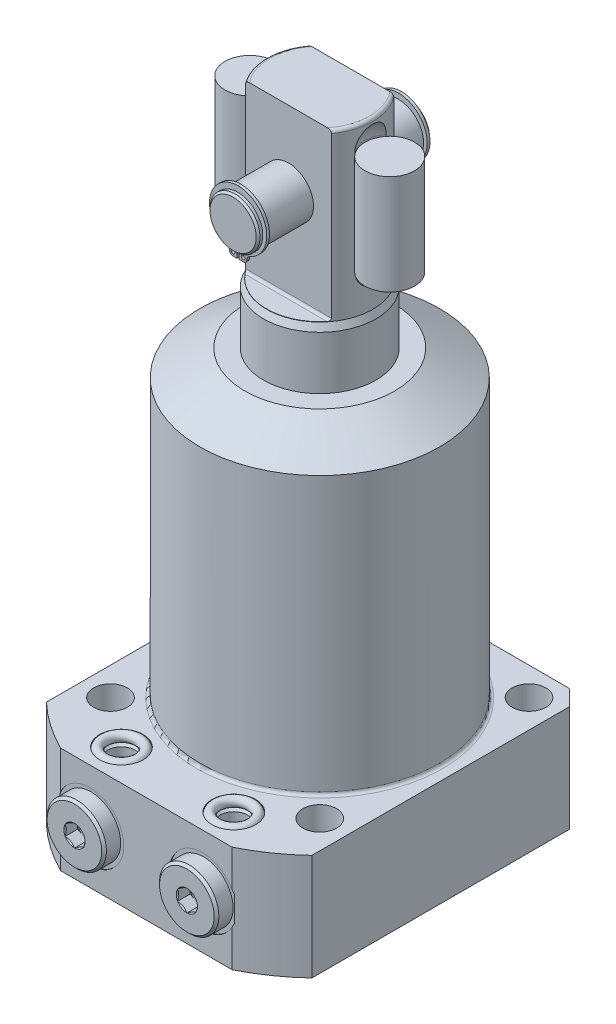
from build123d import *

# Parameters (mm, degrees)
FLATS_DEPTH            = 50
SKETCH23_R             = 0.595
RETAINING_RING_DEPTH   = 0.89
SKETCH24_W             = 7.9375
SKETCH24_H             = 32
SKETCH7_OUTSIDE_W      = 179.488
SKETCH7_OUTSIDE_H      = 179.488
SKETCH7_OUTSIDE_W_2    = 85
SKETCH7_OUTSIDE_H_2    = 98
FLANGE_SIDES_DEPTH     = 35
SKETCH8_R              = 5.4
MOUNTING_HOLES_DEPTH   = 204.2500001
MOUNTING_PATTERN_COUNT = 4
FLANGE_CHAMFER_SIZE    = 5
BODY_FILLET_R          = 1
BSPP_PLUG_HEX_DEPTH    = 4.06
SKETCH16_R             = 1.5


with BuildPart() as part:
    # Sketch1 → PLUNGER (revolve)
    with BuildSketch(Plane.XY, mode=Mode.PRIVATE) as plunger_sk:
        with BuildLine():
            Line((18, 0), (18, 114))
            Line((18, 114), (17, 116.144506921))
            Line((17, 116.144506921), (17, 168.25))
            ThreePointArc((17, 168.25), (16.707106781, 168.957106781), (16, 169.25))
            Line((16, 169.25), (0, 169.25))
            Line((0, 169.25), (0, 0))
            Line((0, 0), (18, 0))
        make_face()
    revolve(plunger_sk.sketch.rotate(Axis((0, -3.075, 0), (0, 1, 0)), 90), axis=Axis((0, -3.075, 0), (0, 1, 0)))  # turned: the seam where the file's is

    # Sketch17 → FLATS (cut, symmetric)
    with BuildSketch(Plane(origin=(0, 0, 0), x_dir=(0, 0, -1), z_dir=(1, 0, 0))):
        with BuildLine():
            Line((10, 169.25), (17, 169.25))
            Line((17, 169.25), (17, 116.25))
            Line((17, 116.25), (10.8, 116.25))
            ThreePointArc((10.8, 116.25), (10.234314575, 116.484314575), (10, 117.05))
            Line((10, 117.05), (10, 169.25))
        make_face()
        with BuildLine():
            Line((-17, 169.25), (-17, 116.25))
            Line((-17, 116.25), (-10.8, 116.25))
            ThreePointArc((-10.8, 116.25), (-10.234314575, 116.484314575), (-10, 117.05))
            Line((-10, 117.05), (-10, 169.25))
            Line((-10, 169.25), (-17, 169.25))
        make_face()
    extrude(amount=FLATS_DEPTH, both=True, mode=Mode.SUBTRACT)

    # Sketch22 → PIVOT_PIN (revolve)
    with BuildSketch(Plane(origin=(0, 0, 0), x_dir=(0, 0, -1), z_dir=(1, 0, 0)), mode=Mode.PRIVATE) as pivot_pin_sk:
        Polygon((-27.75, 152.65), (-27.15, 153.25), (-26.25, 153.25), (-26.25, 152.7175), (-25.25, 152.7175), (-25.25, 153.25), (25.25, 153.25), (25.25, 152.7175), (26.25, 152.7175), (26.25, 153.25), (27.15, 153.25), (27.75, 152.65), (27.75, 145.25), (-27.75, 145.25), align=None)
    revolve(pivot_pin_sk.sketch.rotate(Axis((0, 145.25, 11.568872367), (0, 0, -1)), 90), axis=Axis((0, 145.25, 11.568872367), (0, 0, -1)))  # turned: the seam where the file's is

    # Sketch23 → RETAINING_RING (add)
    with BuildSketch(Plane(origin=(0, 0, -25.25), x_dir=(-1, 0, 0), z_dir=(0, 0, -1))):
        with BuildLine():
            Line((-0.35, 134.70790726), (-1.61, 134.70790726))
            ThreePointArc((-1.61, 134.70790726), (-2.45145707, 135.05645019), (-2.8, 135.89790726))
            ThreePointArc((-2.8, 135.89790726), (-3.016409951, 136.62681713), (-3.595517448, 137.11954157))
            ThreePointArc((-3.595517448, 137.11954157), (-8.984429795, 147.517492161), (0, 155.03))
            ThreePointArc((0, 155.03), (8.984429795, 147.517492161), (3.595517448, 137.11954157))
            ThreePointArc((3.595517448, 137.11954157), (3.016409951, 136.62681713), (2.8, 135.89790726))
            ThreePointArc((2.8, 135.89790726), (2.45145707, 135.05645019), (1.61, 134.70790726))
            Line((1.61, 134.70790726), (0.35, 134.70790726))
            Line((0.35, 134.70790726), (0.35, 137.50790726))
            ThreePointArc((0.35, 137.50790726), (0, 153), (-0.35, 137.50790726))
            Line((-0.35, 137.50790726), (-0.35, 134.70790726))
        make_face()
        with Locations((-1.61, 135.89790726)):
            Circle(SKETCH23_R, mode=Mode.SUBTRACT)
        with Locations(Location((1.61, 135.89790726, 0), (0, 0, 180))):  # turned: the seam where the file's is
            Circle(SKETCH23_R, mode=Mode.SUBTRACT)
    retaining_ring = extrude(amount=RETAINING_RING_DEPTH)

    # RETAINING_RING-OPP: RETAINING_RING across plane
    add(retaining_ring.mirror(Plane.XY))

    # Sketch20 → SPRING_SLOT (revolve, cut)
    with BuildSketch(Plane.XY):
        with BuildLine():
            Line((14.5, 161.75), (14.5, 128.75))
            ThreePointArc((14.5, 128.75), (16.824839924, 123.137339924), (22.4375, 120.8125))
            Line((22.4375, 120.8125), (22.4375, 169.6875))
            ThreePointArc((22.4375, 169.6875), (16.824839924, 167.362660076), (14.5, 161.75))
        make_face()
    spring_slot = revolve(axis=Axis((22.4375, 82.047956129, 0), (0, -1, 0)), mode=Mode.SUBTRACT)

    # SPRING_SLOT_OPP: SPRING_SLOT across plane
    add(spring_slot.mirror(Plane(origin=(0, 0, 0), x_dir=(0, 0, 1), z_dir=(1, 0, 0))), mode=Mode.SUBTRACT)

    # Sketch24 → SPRING (revolve)
    with BuildSketch(Plane.XY):
        with Locations((-18.43875, 145.25)):
            Rectangle(SKETCH24_W, SKETCH24_H)
    spring = revolve(axis=Axis((-22.4075, 84.567834264, 0), (0, -1, 0)))

    # SPRING_OPP: SPRING across plane
    add(spring.mirror(Plane(origin=(0, 0, 0), x_dir=(0, 0, 1), z_dir=(1, 0, 0))))

    # Sketch6 → BODY_REVOLVE (revolve)
    with BuildSketch(Plane.XY, mode=Mode.PRIVATE) as body_revolve_sk:
        Polygon((0, 97), (24, 97), (38.385, 88.694816378), (38.385, 0), (61.915, 0), (61.915, -34), (0, -34), align=None)
    revolve(body_revolve_sk.sketch.rotate(Axis((0, -34, 0), (0, 1, 0)), 90), axis=Axis((0, -34, 0), (0, 1, 0)))  # turned: the seam where the file's is

    # Sketch7 outside → FLANGE_SIDES (cut, through all)
    with BuildSketch(Plane(origin=(0, 0, 0), x_dir=(-1, 0, 0), z_dir=(0, 1, 0))):
        Rectangle(SKETCH7_OUTSIDE_W, SKETCH7_OUTSIDE_H)
        with Locations((0, 6.5)):
            Rectangle(SKETCH7_OUTSIDE_W_2, SKETCH7_OUTSIDE_H_2, mode=Mode.SUBTRACT)
    extrude(amount=-FLANGE_SIDES_DEPTH, mode=Mode.SUBTRACT)

    # Sketch8 → MOUNTING HOLES (cut, through all)
    with BuildSketch(Plane.XZ.offset(34)):
        with Locations(Location((-33.5, 33.5, 0), (0, 0, 270))):  # turned: the seam where the file's is
            Circle(SKETCH8_R)
    mounting_holes = extrude(amount=-MOUNTING_HOLES_DEPTH, mode=Mode.SUBTRACT)

    # MOUNTING_PATTERN: MOUNTING HOLES ×4 about axis
    mounting_pattern_axis = Axis((0, 0, 0), (0, 1, 0))
    for i in range(1, MOUNTING_PATTERN_COUNT):
        add(mounting_holes.rotate(mounting_pattern_axis, i * 360 / MOUNTING_PATTERN_COUNT), mode=Mode.SUBTRACT)

    # FLANGE_CHAMFER
    flange_chamfer_edges = [part.edges().sort_by_distance(p)[0] for p in [
        (-42.5, -17, -42.5),
        (42.5, -17, -42.5),
    ]]
    chamfer(flange_chamfer_edges, length=FLANGE_CHAMFER_SIZE)

    # BODY_FILLET
    body_fillet_edges = [part.edges().sort_by_distance(p)[0] for p in [
        (0, 0, 38.385),
    ]]
    fillet(body_fillet_edges, radius=BODY_FILLET_R)

    # Sketch11 → PORT SPOT FACE (revolve, cut)
    with BuildSketch(Plane.XZ.offset(17), mode=Mode.PRIVATE) as port_spot_face_sk:
        Polygon((-28.75, 55.5), (-28.75, 55.25), (-24.65, 55.25), (-23.945, 54.545), (-23.945, 36.53), (-18, 36.53), (-18, 55.5), align=None)
    port_spot_face = revolve(port_spot_face_sk.sketch.rotate(Axis((-18, -17, 42.971570338), (0, 0, -1)), 180), axis=Axis((-18, -17, 42.971570338), (0, 0, -1)), mode=Mode.SUBTRACT)  # turned: the seam where the file's is

    # Sketch13 → BOTTOM_MANIFOLD_PORT (revolve, cut)
    with BuildSketch(Plane.XY.offset(45.5)):
        Polygon((-22.375, -22), (-22.375, -31), (-23.125, -31.75), (-25, -31.75), (-25, -34), (-18, -34), (-18, -22), align=None)
    bottom_manifold_port = revolve(axis=Axis((-18, 15.209907045, 45.5), (0, -1, 0)), mode=Mode.SUBTRACT)

    # Sketch14 → BSPP_PLUGHEAD (revolve)
    with BuildSketch(Plane.XZ.offset(17)):
        Polygon((-21.4, 60.55), (-26.75, 60.55), (-27.5, 59.8), (-27.5, 55.25), (-22.125, 55.25), (-22.125, 52.7472), (-18, 52.7472), (-18, 52.7482), (-21, 54.550781857), (-21, 60.15), align=None)
    bspp_plughead = revolve(axis=Axis((-18, -17, 32.588064048), (0, 0, 1)))

    # Sketch15 → BSPP_PLUG_HEX (cut)
    with BuildSketch(Plane.XY.offset(60.55)):
        Polygon((-15, -18.732050808), (-15, -15.267949192), (-18, -13.535898385), (-21, -15.267949192), (-21, -18.732050808), (-18, -20.464101615), align=None)
    bspp_plug_hex = extrude(amount=-BSPP_PLUG_HEX_DEPTH, mode=Mode.SUBTRACT)

    # MANIFOLD_TOP_MIRROR: BOTTOM_MANIFOLD_PORT across plane
    add(bottom_manifold_port.mirror(Plane(origin=(0, -17, 0), x_dir=(0, 0, 1), z_dir=(0, -1, 0))), mode=Mode.SUBTRACT)

    # BSPP-MANIFOLD_MIRROR: PORT SPOT FACE, BOTTOM_MANIFOLD_PORT, BSPP_PLUGHEAD, BSPP_PLUG_HEX across plane
    add(port_spot_face.mirror(Plane(origin=(0, 0, 0), x_dir=(0, 0, 1), z_dir=(1, 0, 0))), mode=Mode.SUBTRACT)
    add(bottom_manifold_port.mirror(Plane(origin=(0, 0, 0), x_dir=(0, 0, 1), z_dir=(1, 0, 0))), mode=Mode.SUBTRACT)
    add(bspp_plughead.mirror(Plane(origin=(0, 0, 0), x_dir=(0, 0, 1), z_dir=(1, 0, 0))))
    add(bspp_plug_hex.mirror(Plane(origin=(0, 0, 0), x_dir=(0, 0, 1), z_dir=(1, 0, 0))), mode=Mode.SUBTRACT)

    # BSPP-MANIFOLD_MIRROR copy 1 sketch → BSPP-MANIFOLD_MIRROR copy 1 (revolve, cut)
    with BuildSketch(Plane(origin=(0, -34, 45.5), x_dir=(-1, 0, 0), z_dir=(0, 0, 1))):
        Polygon((-22.375, -22), (-22.375, -31), (-23.125, -31.75), (-25, -31.75), (-25, -34), (-18, -34), (-18, -22), align=None)
    revolve(axis=Axis((18, -49.209907045, 45.5), (0, 1, 0)), mode=Mode.SUBTRACT)


with BuildPart() as body_2:
    # Sketch16 → MANIFOLD_O-RING (revolve)
    with BuildSketch(Plane.XY.offset(45.5)):
        with Locations((-23.5, -33.25)):
            Circle(SKETCH16_R)
    revolve(axis=Axis((-18, 9.321927472, 45.5), (0, -1, 0)))


with BuildPart() as body_3:
    # MANIFOLD_O-RING_MIRROR: mirrored copy
    add(body_2.part.mirror(Plane(origin=(0, 0, 0), x_dir=(0, 0, 1), z_dir=(1, 0, 0))))


with BuildPart() as body_4:
    # MANIFOLD_O-RING_MIRROR_TOP: mirrored copy
    add(body_2.part.mirror(Plane(origin=(0, -17, 0), x_dir=(0, 0, 1), z_dir=(0, -1, 0))))


with BuildPart() as body_5:
    # MANIFOLD_O-RING_MIRROR_TOP 2: mirrored copy
    add(body_3.part.mirror(Plane(origin=(0, -17, 0), x_dir=(0, 0, 1), z_dir=(0, -1, 0))))


solid = Compound([part.part, body_2.part, body_3.part, body_4.part, body_5.part])
